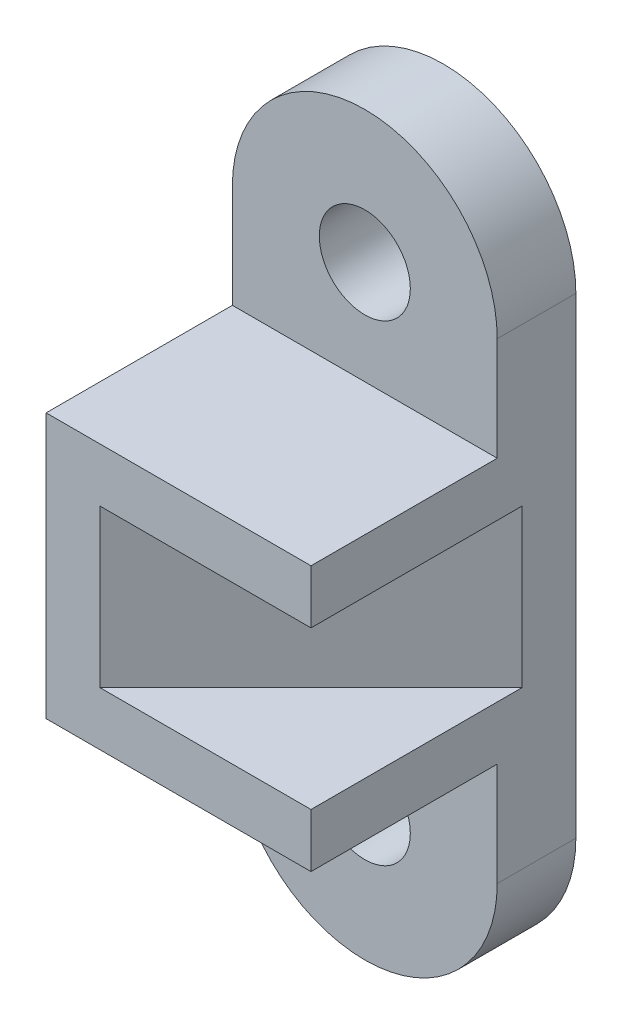
from build123d import *

# Parameters (mm, degrees)
SKETCH1_R           = 11
BOSS_EXTRUDE1_DEPTH = 19
BOSS_EXTRUDE2_DEPTH = 45
CUT_EXTRUDE1_DEPTH  = 51
BOSS_EXTRUDE3_REACH = 110


with BuildPart() as part:
    # Sketch1 → Boss-Extrude1 (new body)
    with BuildSketch(Plane(origin=(0, 0, 0), x_dir=(0, 1, 0), z_dir=(0, 0, 1))):
        with BuildLine():
            Line((0, 0), (114, 0))
            ThreePointArc((114, 0), (146, 32), (114, 64))
            Line((114, 64), (0, 64))
            ThreePointArc((0, 64), (-32, 32), (0, 0))
        make_face()
        with Locations((0, 32)):
            Circle(SKETCH1_R, mode=Mode.SUBTRACT)
        with Locations((114, 32)):
            Circle(SKETCH1_R, mode=Mode.SUBTRACT)
    extrude(amount=BOSS_EXTRUDE1_DEPTH)

    # Sketch2 → Boss-Extrude2 (add)
    with BuildSketch(Plane.XY.offset(19)):
        Polygon((0, 57), (0, 89), (-64, 89), (-64, 25), (0, 25), align=None)
    extrude(amount=BOSS_EXTRUDE2_DEPTH)

    # Sketch3 → Cut-Extrude1 (cut)
    with BuildSketch(Plane.XY.offset(64)):
        Polygon((-13, 76), (0, 76), (0, 38), (-13, 38), (-51, 38), (-51, 76), align=None)
    extrude(amount=-CUT_EXTRUDE1_DEPTH, mode=Mode.SUBTRACT)

    # Sketch4 → Boss-Extrude3 (add, up to next)
    with BuildSketch(Plane(origin=(0, 38, 0), x_dir=(1, 0, 0), z_dir=(0, 1, 0)), mode=Mode.PRIVATE) as boss_extrude3_sk1:
        Polygon((0, -13), (-51, -64), (-51, -13), align=None)
    boss_extrude3_tool1 = extrude(boss_extrude3_sk1.sketch, amount=BOSS_EXTRUDE3_REACH, mode=Mode.PRIVATE) - part.part
    add(boss_extrude3_tool1.solids().sort_by_distance((-34, 38, 30))[0])


solid = part.part
